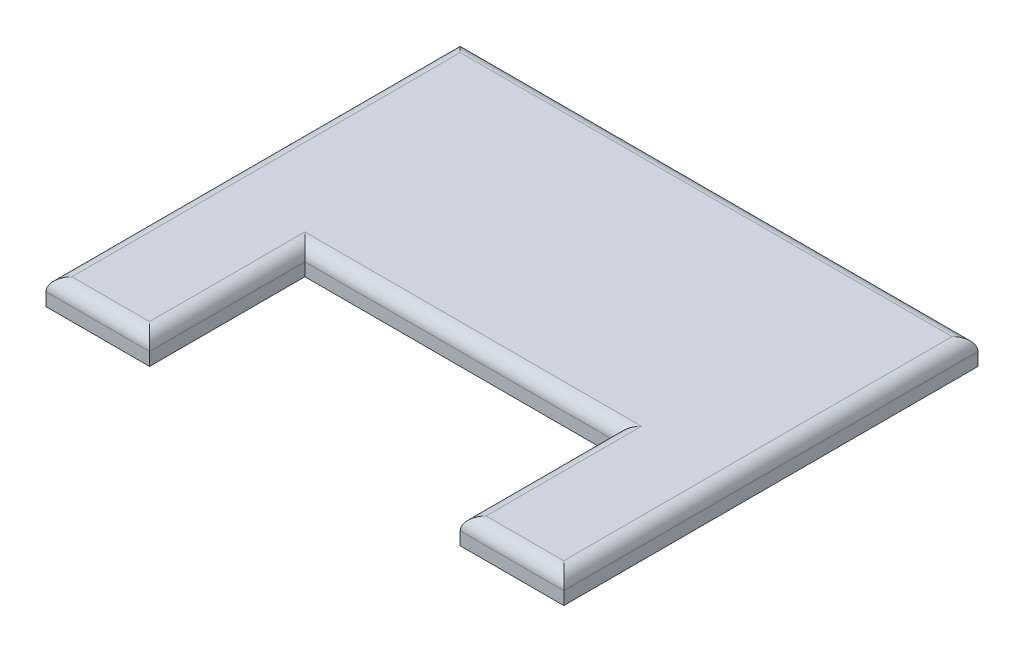
from build123d import *

# Parameters (mm, degrees)
BOSS_EXTRUDE1_DEPTH = 10
FILLET1_R           = 5


with BuildPart() as part:
    # Sketch1 → Boss-Extrude1 (new body)
    with BuildSketch(Plane(origin=(0, 0, 0), x_dir=(1, 0, 0), z_dir=(0, 1, 0))):
        Polygon((-60, -80), (-60, -20), (60, -20), (60, -80), (100, -80), (100, 80), (-100, 80), (-100, -80), align=None)
    extrude(amount=BOSS_EXTRUDE1_DEPTH)

    # Fillet1
    fillet1_edges = [part.edges().sort_by_distance(p)[0] for p in [
        (0, 10, -80),
        (-100, 10, 0),
        (-80, 10, 80),
        (-60, 10, 50),
        (0, 10, 20),
        (60, 10, 50),
        (80, 10, 80),
        (100, 10, 0),
    ]]
    fillet(fillet1_edges, radius=FILLET1_R)


solid = part.part
